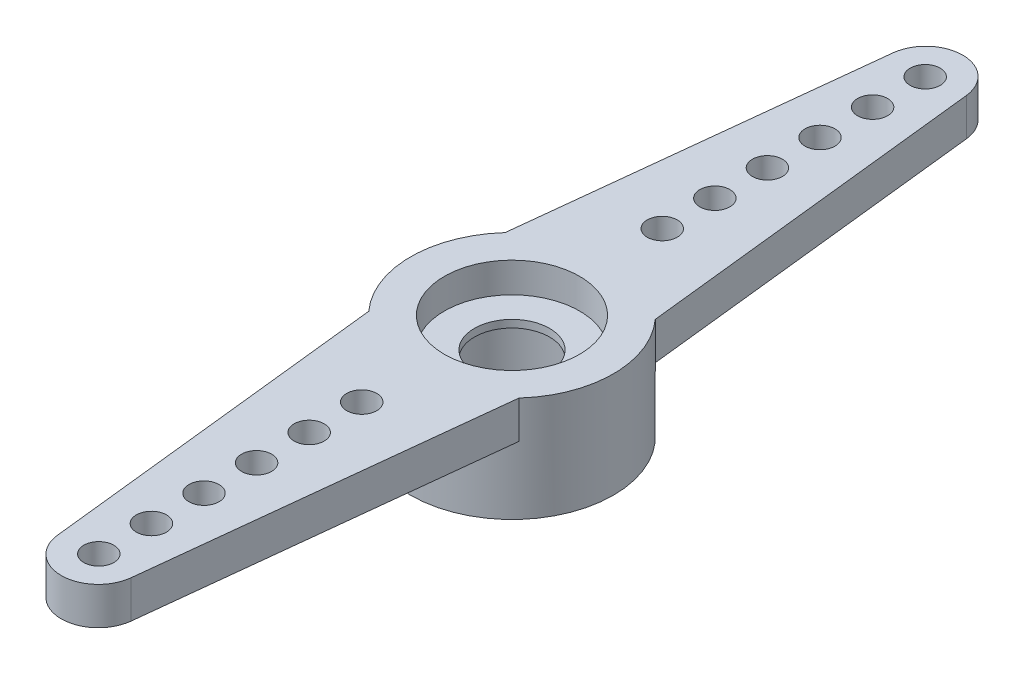
from build123d import *
from build123d.topology import SkipClean

# Parameters (mm, degrees)
SKETCH1_R               = 3.429
SKETCH1_R_2             = 2.286
BOSS_EXTRUDE1_DEPTH     = 3.556
BOSS_EXTRUDE2_START     = -1.27
BOSS_EXTRUDE2_DEPTH     = 1.27
BOSS_EXTRUDE3_START     = -1.27
SKETCH2_3_R             = 2.286
SKETCH2_3_R_2           = 1.27
BOSS_EXTRUDE3_DEPTH     = 0.254
SKETCH3_R               = 0.508
CUT_EXTRUDE1_DEPTH      = 17.020635974
LPATTERN1_COUNT         = 6
LPATTERN1_PITCH         = 1.778
CUT_EXTRUDE2_DEPTH      = 17.020635974
CUT_EXTRUDE2_DEPTH_BACK = 17.020635974
SKETCH4_W               = 4.326879353
SKETCH4_H               = 6.724216597


with BuildPart() as part:
    # Sketch1 → Boss-Extrude1 (new body)
    with BuildSketch(Plane(origin=(0, 0, 0), x_dir=(1, 0, 0), z_dir=(0, 1, 0))):
        Circle(SKETCH1_R)
        Circle(SKETCH1_R_2, mode=Mode.SUBTRACT)
    extrude(amount=BOSS_EXTRUDE1_DEPTH)

    # Sketch2 → Boss-Extrude2 (add)
    with BuildSketch(Plane(origin=(0, 3.556, 0), x_dir=(1, 0, 0), z_dir=(0, 1, 0)).offset(BOSS_EXTRUDE2_START)):
        with BuildLine():
            ThreePointArc((-2.54, 2.303571358), (0, 3.429), (2.54, 2.303571358))
            Line((2.54, 2.303571358), (1.244511661, 14.124427226))
            ThreePointArc((1.244511661, 14.124427226), (0, 15.24), (-1.244511661, 14.124427226))
            Line((-1.244511661, 14.124427226), (-2.54, 2.303571358))
        make_face()
    extrude(amount=BOSS_EXTRUDE2_DEPTH)

    # Sketch2_3 → Boss-Extrude3 (add)
    with BuildSketch(Plane(origin=(0, 3.556, 0), x_dir=(1, 0, 0), z_dir=(0, 1, 0)).offset(BOSS_EXTRUDE3_START)):
        Circle(SKETCH2_3_R)
        Circle(SKETCH2_3_R_2, mode=Mode.SUBTRACT)
    extrude(amount=BOSS_EXTRUDE3_DEPTH)

    # Sketch3 → Cut-Extrude1 (cut, through all)
    with BuildSketch(Plane(origin=(0, 3.556, 0), x_dir=(1, 0, 0), z_dir=(0, 1, 0))):
        with Locations((0, 5.08)):
            Circle(SKETCH3_R)
    cut_extrude1 = extrude(amount=-CUT_EXTRUDE1_DEPTH, mode=Mode.SUBTRACT)

    # LPattern1: Cut-Extrude1 ×6
    with Locations(*[(0, 0, -i * LPATTERN1_PITCH) for i in range(1, LPATTERN1_COUNT)]):
        add(cut_extrude1, mode=Mode.SUBTRACT)

    # Sketch4 → Cut-Extrude2 (cut, two sides: drawn at the far end of the back side and taken through both)
    with BuildSketch(Plane(origin=(0, 0, 0), x_dir=(0, 0, -1), z_dir=(1, 0, 0)).offset(-CUT_EXTRUDE2_DEPTH_BACK)):
        with Locations((-2.163439677, 3.362108299)):
            Rectangle(SKETCH4_W, SKETCH4_H)
    extrude(amount=CUT_EXTRUDE2_DEPTH + CUT_EXTRUDE2_DEPTH_BACK, mode=Mode.SUBTRACT)

    # Mirror1: part across plane


with BuildPart() as part_1:
    with SkipClean():  # the faces are left unmerged after this step: merging them gives an invalid solid
        add(part.part)
        add(part.part.mirror(Plane.XY))


solid = part_1.part
